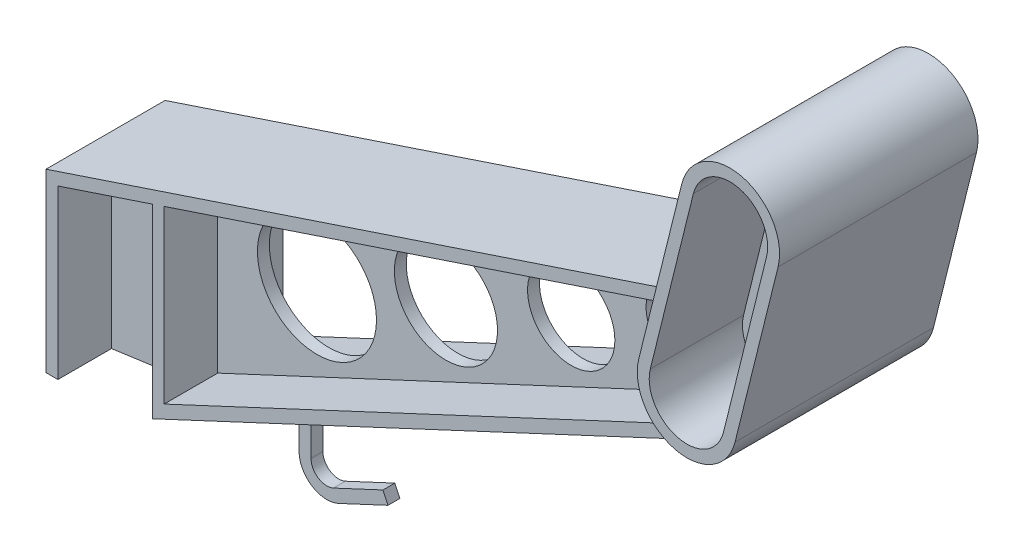
from build123d import *

# Parameters (mm, degrees)
ESTRUSIONE_ESTRUSIONE1_DEPTH = 15
TAGLIO_ESTRUSIONE1_DEPTH     = 13.5
SCHIZZO3_R                   = 15
SCHIZZO3_R_2                 = 13
SCHIZZO3_R_3                 = 11
SCHIZZO3_R_4                 = 9
TAGLIO_ESTRUSIONE2_DEPTH     = 17.5
ESTRUSIONE_ESTRUSIONE3_DEPTH = 25
TAGLIO_ESTRUSIONE4_DEPTH     = 23.5
TAGLIO_ESTRUSIONE5_DEPTH     = 23.5
TAGLIO_ESTRUSIONE6_DEPTH     = 27.5
ESTRUSIONE_SOTTILE2_START    = -15
ESTRUSIONE_SOTTILE2_DEPTH    = 30
ESTRUSIONE_ESTRUSIONE4_DEPTH = 1.5
ESTRUSIONE_SOTTILE3_DEPTH    = 3


with BuildPart() as part:
    # Schizzo1 → Estrusione-Estrusione1 (new body, symmetric)
    with BuildSketch(Plane.XY):
        Polygon((-61.953104657, -55.142919533), (-61.953104657, -5.142919533), (88.046895343, 44.857080467), (88.046895343, 14.857080467), align=None)
    extrude(amount=ESTRUSIONE_ESTRUSIONE1_DEPTH, both=True)

    # Schizzo2 → Taglio-Estrusione1 (cut)
    with BuildSketch(Plane.XY.offset(15)):
        Polygon((85.046895343, 16.767669539), (85.046895343, 40.694802807), (-58.953104657, -7.305197193), (-58.953104657, -50.432330461), align=None)
    taglio_estrusione1 = extrude(amount=-TAGLIO_ESTRUSIONE1_DEPTH, mode=Mode.SUBTRACT)

    # Specchia1: Taglio-Estrusione1 across plane
    add(taglio_estrusione1.mirror(Plane.XY), mode=Mode.SUBTRACT)

    # Schizzo3 → Taglio-Estrusione2 (cut, through all)
    with BuildSketch(Plane.XY.offset(1.5)):
        with Locations((-33.953104657, -18.868763827)):
            Circle(SCHIZZO3_R)
        with Locations((-1.456420476, -5.870090155)):
            Circle(SCHIZZO3_R_2)
        with Locations((30.111787014, 6.757192842)):
            Circle(SCHIZZO3_R_3)
        with Locations((57.966087741, 17.898913132)):
            Circle(SCHIZZO3_R_4)
    extrude(amount=-TAGLIO_ESTRUSIONE2_DEPTH, mode=Mode.SUBTRACT)

    # Schizzo4 → Estrusione-Estrusione3 (add, symmetric)
    with BuildSketch(Plane.XY):
        with BuildLine():
            Line((70.629518485, 29.197898059), (81.478220515, 72.870608809))
            ThreePointArc((81.478220515, 72.870608809), (96.623057398, 81.988389009), (105.740837598, 66.843552126))
            Line((105.740837598, 66.843552126), (94.892135568, 23.170841376))
            ThreePointArc((94.892135568, 23.170841376), (79.747298685, 14.053061176), (70.629518485, 29.197898059))
        make_face()
    extrude(amount=ESTRUSIONE_ESTRUSIONE3_DEPTH, both=True)

    # Schizzo5 → Taglio-Estrusione4 (cut)
    with BuildSketch(Plane.XY.offset(25)):
        with BuildLine():
            Line((91.980621518, 23.894088178), (102.829323548, 67.566798928))
            ThreePointArc((102.829323548, 67.566798928), (95.899810596, 79.076874959), (84.389734565, 72.147362007))
            Line((84.389734565, 72.147362007), (73.541032535, 28.474651257))
            ThreePointArc((73.541032535, 28.474651257), (80.470545487, 16.964575226), (91.980621518, 23.894088178))
        make_face()
    extrude(amount=-TAGLIO_ESTRUSIONE4_DEPTH, mode=Mode.SUBTRACT)

    # Schizzo6 → Taglio-Estrusione5 (cut)
    with BuildSketch(Plane(origin=(0, 0, -25), x_dir=(-1, 0, 0), z_dir=(0, 0, -1))):
        with BuildLine():
            Line((-73.541032535, 28.474651257), (-84.389734565, 72.147362007))
            ThreePointArc((-84.389734565, 72.147362007), (-95.899810596, 79.076874959), (-102.829323548, 67.566798928))
            Line((-102.829323548, 67.566798928), (-91.980621518, 23.894088178))
            ThreePointArc((-91.980621518, 23.894088178), (-80.470545487, 16.964575226), (-73.541032535, 28.474651257))
        make_face()
    extrude(amount=-TAGLIO_ESTRUSIONE5_DEPTH, mode=Mode.SUBTRACT)

    # Schizzo7 → Taglio-Estrusione6 (cut, through all)
    with BuildSketch(Plane.XY.offset(1.5)):
        with BuildLine():
            Line((76.937798926, 27.630863321), (87.786500957, 71.303574071))
            ThreePointArc((87.786500957, 71.303574071), (95.056022661, 75.680108567), (99.432557157, 68.410586863))
            Line((99.432557157, 68.410586863), (88.583855126, 24.737876113))
            ThreePointArc((88.583855126, 24.737876113), (81.314333422, 20.361341617), (76.937798926, 27.630863321))
        make_face()
    extrude(amount=-TAGLIO_ESTRUSIONE6_DEPTH, mode=Mode.SUBTRACT)

    # Schizzo8 → Estrusione-Sottile2 (add)
    with BuildSketch(Plane.XY.offset(ESTRUSIONE_SOTTILE2_START)):
        Polygon((-61.953104657, -5.142919533), (-88.727527571, -14.067727171), (-88.727527571, -58.470604197), (-85.727527571, -58.470604197), (-85.727527571, -16.230004831), (-61.004421359, -7.988969427), align=None)
    extrude(amount=ESTRUSIONE_SOTTILE2_DEPTH)

    # Schizzo9 → Estrusione-Estrusione4 (add, symmetric)
    with BuildSketch(Plane.XY):
        Polygon((-85.727527571, -58.470604197), (-61.953104657, -55.142919533), (-61.953104657, -8.305197193), (-85.727527571, -16.230004831), align=None)
    extrude(amount=ESTRUSIONE_ESTRUSIONE4_DEPTH, both=True)

    # Schizzo11 → Estrusione-Sottile3 (add)
    with BuildSketch(Plane.XY):
        with BuildLine():
            Line((-33.953104657, -42.076252866), (-33.953104657, -55.795467437))
            ThreePointArc((-33.953104657, -55.795467437), (-32.101805724, -59.169350026), (-28.261562796, -59.420199997))
            Line((-28.261562796, -59.420199997), (-15.829441857, -53.618543559))
            Line((-15.829441857, -53.618543559), (-14.560785461, -56.337092979))
            Line((-14.560785461, -56.337092979), (-26.9929064, -62.138749417))
            ThreePointArc((-26.9929064, -62.138749417), (-33.713331525, -61.699761968), (-36.953104657, -55.795467437))
            Line((-36.953104657, -55.795467437), (-36.953104657, -42.076252866))
            Line((-36.953104657, -42.076252866), (-33.953104657, -42.076252866))
        make_face()
    extrude(amount=ESTRUSIONE_SOTTILE3_DEPTH)


solid = part.part
